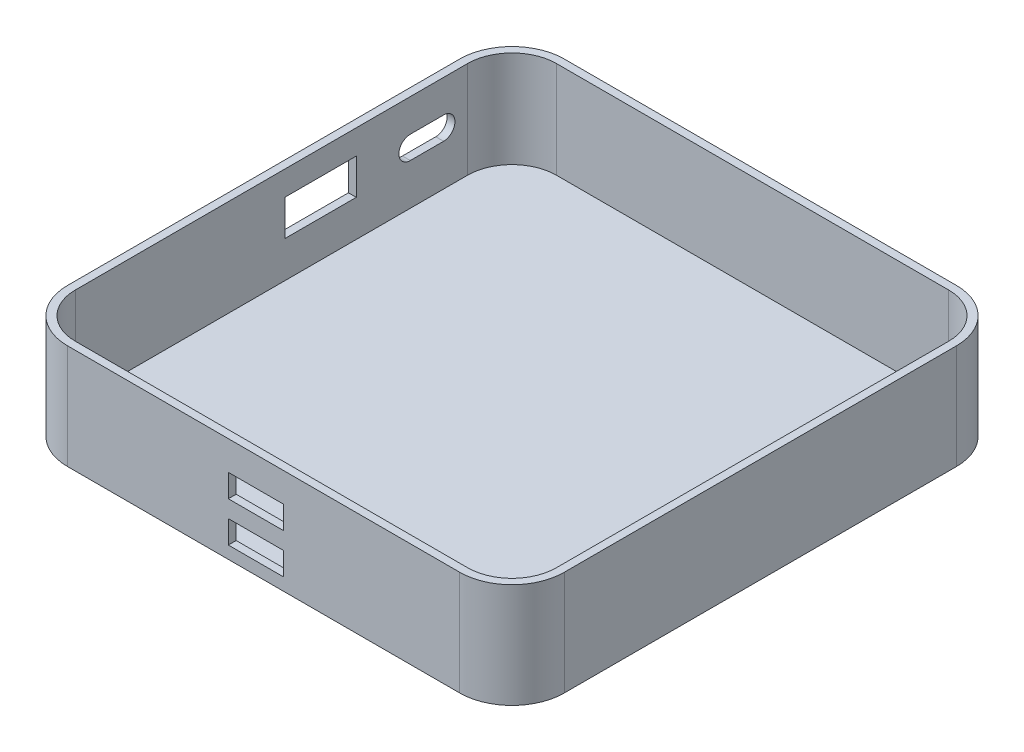
from build123d import *

# Parameters (mm, degrees)
SKETCH1_W           = 95
SKETCH1_H           = 95
BOSS_EXTRUDE1_DEPTH = 20
FILLET1_R           = 10
CUT_EXTRUDE5_DEPTH  = 18.5
CUT_EXTRUDE6_DEPTH  = 10
SKETCH6_W           = 13.621181439
SKETCH6_H           = 6.835350155
CUT_EXTRUDE7_DEPTH  = 10
SKETCH9_W           = 10.583669907
SKETCH9_H           = 4.379449617
CUT_EXTRUDE10_DEPTH = 10


with BuildPart() as part:
    # Sketch1 → Boss-Extrude1 (new body)
    with BuildSketch(Plane(origin=(0, 0, 0), x_dir=(1, 0, 0), z_dir=(0, 1, 0))):
        Rectangle(SKETCH1_W, SKETCH1_H)
    extrude(amount=BOSS_EXTRUDE1_DEPTH)

    # Fillet1
    fillet1_edges = [part.edges().sort_by_distance(p)[0] for p in [
        (47.5, 10, 47.5),
        (-47.5, 10, 47.5),
        (-47.5, 10, -47.5),
        (47.5, 10, -47.5),
    ]]
    fillet(fillet1_edges, radius=FILLET1_R)

    # Sketch4 → Cut-Extrude5 (cut)
    with BuildSketch(Plane(origin=(0, 20, 0), x_dir=(1, 0, 0), z_dir=(0, 1, 0))):
        with BuildLine():
            Line((37.5, 46), (-37.5, 46))
            ThreePointArc((-37.5, 46), (-43.51040764, 43.51040764), (-46, 37.5))
            Line((-46, 37.5), (-46, -37.5))
            ThreePointArc((-46, -37.5), (-43.51040764, -43.51040764), (-37.5, -46))
            Line((-37.5, -46), (37.5, -46))
            ThreePointArc((37.5, -46), (43.51040764, -43.51040764), (46, -37.5))
            Line((46, -37.5), (46, 37.5))
            ThreePointArc((46, 37.5), (43.51040764, 43.51040764), (37.5, 46))
        make_face()
    extrude(amount=-CUT_EXTRUDE5_DEPTH, mode=Mode.SUBTRACT)

    # Sketch5 → Cut-Extrude6 (cut)
    with BuildSketch(Plane.ZY.offset(47.5)):
        with BuildLine():
            Line((-32.917062514, 13.76355051), (-26.545864744, 13.76355051))
            ThreePointArc((-26.545864744, 13.76355051), (-24.370980604, 11.588666369), (-26.545864744, 9.413782229))
            Line((-26.545864744, 9.413782229), (-32.917062514, 9.413782229))
            ThreePointArc((-32.917062514, 9.413782229), (-35.091946654, 11.588666369), (-32.917062514, 13.76355051))
        make_face()
    extrude(amount=-CUT_EXTRUDE6_DEPTH, mode=Mode.SUBTRACT)

    # Sketch6 → Cut-Extrude7 (cut)
    with BuildSketch(Plane.ZY.offset(47.5)):
        with Locations((-9.409539708, 11.899364103)):
            Rectangle(SKETCH6_W, SKETCH6_H)
    extrude(amount=-CUT_EXTRUDE7_DEPTH, mode=Mode.SUBTRACT)

    # Sketch9 → Cut-Extrude10 (cut)
    with BuildSketch(Plane.XY.offset(47.5)):
        with Locations((-1.457227674, 4.56970852)):
            Rectangle(SKETCH9_W, SKETCH9_H)
        with Locations((-1.457227674, 12.233745351)):
            Rectangle(SKETCH9_W, SKETCH9_H)
    extrude(amount=-CUT_EXTRUDE10_DEPTH, mode=Mode.SUBTRACT)


solid = part.part
